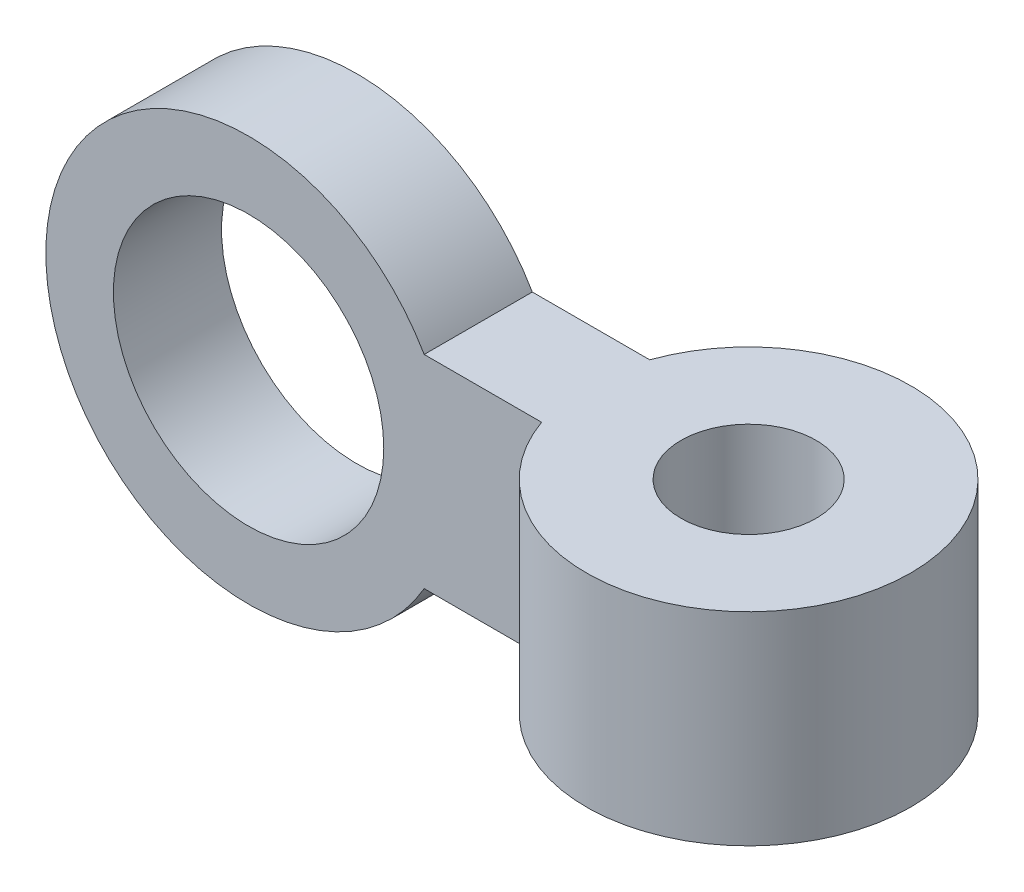
from build123d import *

# Parameters (mm, degrees)
SKETCH1_R           = 10
BOSS_EXTRUDE1_DEPTH = 8
BOSS_EXTRUDE2_DEPTH = 15
SKETCH3_R           = 5
CUT_EXTRUDE1_DEPTH  = 23.5


with BuildPart() as part:
    # Sketch1 → Boss-Extrude1 (new body)
    with BuildSketch(Plane.XY):
        with BuildLine():
            Line((12.990381057, 7.5), (32.990381057, 7.5))
            Line((32.990381057, 7.5), (32.990381057, -7.5))
            Line((32.990381057, -7.5), (12.990381057, -7.5))
            ThreePointArc((12.990381057, -7.5), (-15, 0), (12.990381057, 7.5))
        make_face()
        Circle(SKETCH1_R, mode=Mode.SUBTRACT)
    extrude(amount=BOSS_EXTRUDE1_DEPTH)

    # Sketch2 → Boss-Extrude2 (add)
    with BuildSketch(Plane(origin=(0, 7.5, 0), x_dir=(1, 0, 0), z_dir=(0, 1, 0))):
        with BuildLine():
            ThreePointArc((21.676672558, -8), (44.990381057, -4), (21.676672558, 0))
            Line((21.676672558, 0), (32.990381057, 0))
            Line((32.990381057, 0), (32.990381057, -8))
            Line((32.990381057, -8), (21.676672558, -8))
        make_face()
    extrude(amount=-BOSS_EXTRUDE2_DEPTH)

    # Sketch3 → Cut-Extrude1 (cut, through all)
    with BuildSketch(Plane(origin=(0, 7.5, 0), x_dir=(1, 0, 0), z_dir=(0, 1, 0))):
        with Locations((32.990381057, -4)):
            Circle(SKETCH3_R)
    extrude(amount=-CUT_EXTRUDE1_DEPTH, mode=Mode.SUBTRACT)


solid = part.part
